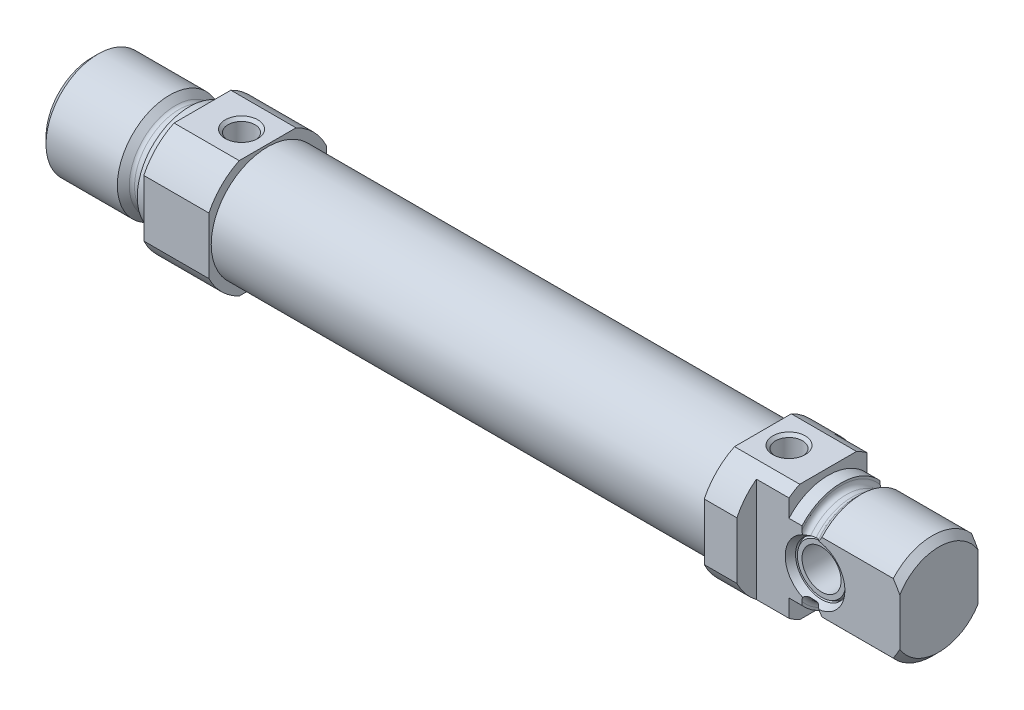
from build123d import *

# Parameters (mm, degrees)
BOSS_EXTRUDE1_DEPTH     = 10
SKETCH3_W               = 76
SKETCH3_H               = 8.65
SKETCH4_W               = 18
SKETCH4_H               = 18
BOSS_EXTRUDE2_DEPTH     = 10
SKETCH5_W               = 10
SKETCH5_H               = 10
CUT_EXTRUDE1_DEPTH      = 10
CUT_EXTRUDE1_DEPTH_BACK = 10
HOLE1_D                 = 4.134
HOLE1_DEPTH             = 9
HOLE1_CSINK_D           = 5
HOLE1_CSINK_ANGLE       = 90
HOLE2_D                 = 4.134
HOLE2_DEPTH             = 11
HOLE2_CSINK_D           = 5
HOLE2_CSINK_ANGLE       = 90
HOLE2_TIP               = 1.193383006


with BuildPart() as part:
    # Sketch1 → Revolve1 (revolve)
    with BuildSketch(Plane.XY):
        with BuildLine():
            Line((0, 0), (0, 7))
            Line((0, 7), (1, 8))
            Line((1, 8), (11.95, 8))
            Line((11.95, 8), (12.865685425, 7.084314575))
            ThreePointArc((12.865685425, 7.084314575), (13.125224104, 6.910896374), (13.43137085, 6.85))
            Line((13.43137085, 6.85), (14.2, 6.85))
            ThreePointArc((14.2, 6.85), (14.765685425, 7.084314575), (15, 7.65))
            Line((15, 7.65), (15, 8))
            Line((15, 8), (17, 8))
            Line((17, 8), (17, 0))
            Line((17, 0), (0, 0))
        make_face()
    revolve(axis=Axis((17, 0, 0), (-1, 0, 0)))

    # Sketch2 → Boss-Extrude1 (add)
    with BuildSketch(Plane(origin=(17, 0, 0), x_dir=(0, 0, -1), z_dir=(1, 0, 0))):
        with BuildLine():
            Line((-4.358898944, -9), (4.358898944, -9))
            ThreePointArc((4.358898944, -9), (7.071067812, -7.071067812), (9, -4.358898944))
            Line((9, -4.358898944), (9, 4.358898944))
            ThreePointArc((9, 4.358898944), (7.071067812, 7.071067812), (4.358898944, 9))
            Line((4.358898944, 9), (-4.358898944, 9))
            ThreePointArc((-4.358898944, 9), (-7.071067812, 7.071067812), (-9, 4.358898944))
            Line((-9, 4.358898944), (-9, -4.358898944))
            ThreePointArc((-9, -4.358898944), (-7.071067812, -7.071067812), (-4.358898944, -9))
        make_face()
    extrude(amount=BOSS_EXTRUDE1_DEPTH)

    # Sketch3 → Revolve2 (revolve)
    with BuildSketch(Plane.XY):
        with Locations((65, 4.325)):
            Rectangle(SKETCH3_W, SKETCH3_H)
    revolve(axis=Axis((103, 0, 0), (-1, 0, 0)))

    # Sketch4 → Boss-Extrude2 (add)
    with BuildSketch(Plane(origin=(103, 0, 0), x_dir=(0, 0, -1), z_dir=(1, 0, 0))):
        Rectangle(SKETCH4_W, SKETCH4_H)
    extrude(amount=BOSS_EXTRUDE2_DEPTH)

    # Sketch5 → Cut-Revolve1 (revolve, cut)
    with BuildSketch(Plane.XY):
        with Locations((108, 15)):
            Rectangle(SKETCH5_W, SKETCH5_H)
    revolve(axis=Axis((113, 0, 0), (-1, 0, 0)), mode=Mode.SUBTRACT)

    # Sketch6 → Revolve3 (revolve)
    with BuildSketch(Plane.XY):
        with BuildLine():
            Line((113, 0), (113, 8))
            Line((113, 8), (115, 8))
            Line((115, 8), (115, 7.65))
            ThreePointArc((115, 7.65), (115.234314575, 7.084314575), (115.8, 6.85))
            Line((115.8, 6.85), (116.56862915, 6.85))
            ThreePointArc((116.56862915, 6.85), (116.874775896, 6.910896374), (117.134314575, 7.084314575))
            Line((117.134314575, 7.084314575), (118.05, 8))
            Line((118.05, 8), (129, 8))
            Line((129, 8), (130, 7))
            Line((130, 7), (130, 0))
            Line((130, 0), (113, 0))
        make_face()
    revolve(axis=Axis((130, 0, 0), (-1, 0, 0)))

    # Sketch7 → Cut-Extrude1 (cut, two sides: drawn at the far end of the back side and taken through both)
    with BuildSketch(Plane(origin=(0, 0, 0), x_dir=(1, 0, 0), z_dir=(0, 1, 0)).offset(-CUT_EXTRUDE1_DEPTH_BACK)):
        Polygon((108, 18), (108, 6), (130, 6), (130, -6), (108, -6), (108, -18), (142, -18), (142, 18), align=None)
    extrude(amount=CUT_EXTRUDE1_DEPTH + CUT_EXTRUDE1_DEPTH_BACK, mode=Mode.SUBTRACT)

    # Sketch8 → Cut-Revolve2 (revolve, cut)
    with BuildSketch(Plane(origin=(117, 0, 0), x_dir=(0, 0, -1), z_dir=(1, 0, 0))):
        Polygon((-6.2, 0), (-6.2, 4.692820323), (-5, 4), (-4.5, 4), (-5, 3.711324865), (-5, 3), (5, 3), (5, 3.711324865), (4.5, 4), (5, 4), (6.2, 4.692820323), (6.2, 0), align=None)
    revolve(axis=Axis((117, 0, -5), (0, 0, 1)), mode=Mode.SUBTRACT)

    # Hole1
    with Locations(Plane(origin=(0, 9, 0), x_dir=(1, 0, 0), z_dir=(0, 1, 0))):
        with Locations((23, 0)):
            CounterSinkHole(HOLE1_D / 2, HOLE1_CSINK_D / 2, depth=HOLE1_DEPTH, counter_sink_angle=HOLE1_CSINK_ANGLE)

    # Hole2
    with Locations(Plane(origin=(0, 9, 0), x_dir=(1, 0, 0), z_dir=(0, 1, 0))):
        with Locations((107, 0)):
            CounterSinkHole(HOLE2_D / 2, HOLE2_CSINK_D / 2, depth=HOLE2_DEPTH, counter_sink_angle=HOLE2_CSINK_ANGLE)
            with Locations((0, 0, -(HOLE2_DEPTH + HOLE2_TIP / 2))):  # 120° drill point
                Cone(0, HOLE2_D / 2, HOLE2_TIP, mode=Mode.SUBTRACT)

    # Sketch13 → Cut-Revolve3 (revolve, cut)
    with BuildSketch(Plane.XY):
        Polygon((-5, 0), (-5, 3), (41.2, 3), (41.2, 8), (85.2, 8), (85.2, 0), align=None)
    revolve(axis=Axis((85.2, 0, 0), (-1, 0, 0)), mode=Mode.SUBTRACT)


solid = part.part
